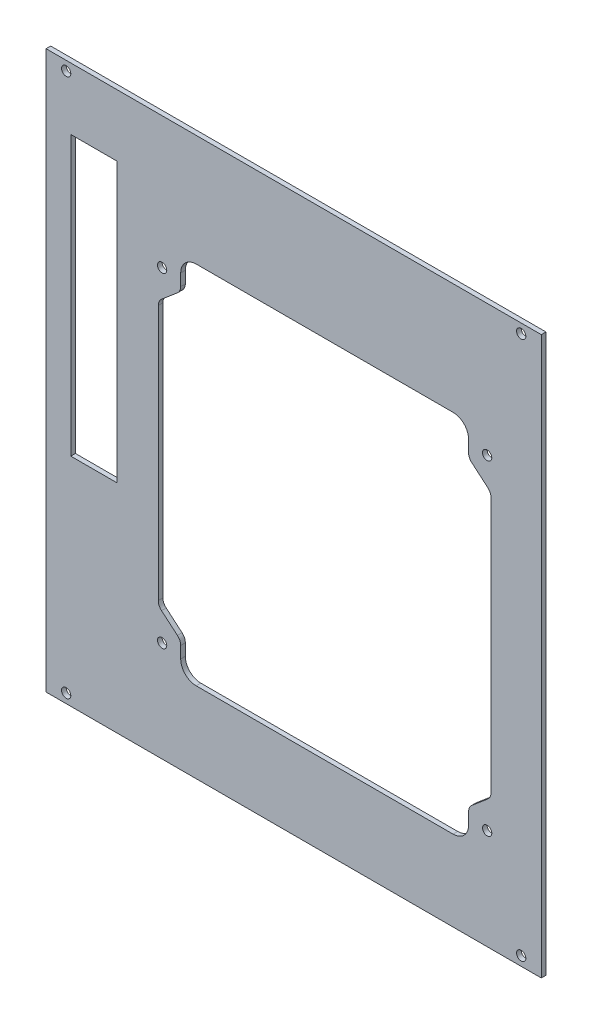
from build123d import *

# Parameters (mm, degrees)
SKETCH_1_W      = 1600
SKETCH_1_H      = 1800
SKETCH_1_R      = 15
SKETCH_1_W_2    = 150
SKETCH_1_H_2    = 900
EXTRUDE_1_DEPTH = 3
SCALE_1_SCALE_X = 0.1
SCALE_1_SCALE_Y = 0.1
SCALE_1_SCALE_Z = 0.5


with BuildPart() as part:
    # 草图1 → 凸台-拉伸1 (new body)
    with BuildSketch(Plane.XY):
        with Locations((-690.069262504, 0)):
            Rectangle(SKETCH_1_W, SKETCH_1_H)
        with Locations((-1425.069262504, 870)):
            Circle(SKETCH_1_R, mode=Mode.SUBTRACT)
        with Locations((-1425.069262504, -870)):
            Circle(SKETCH_1_R, mode=Mode.SUBTRACT)
        with Locations((44.930737496, -870)):
            Circle(SKETCH_1_R, mode=Mode.SUBTRACT)
        with Locations((44.930737496, 870)):
            Circle(SKETCH_1_R, mode=Mode.SUBTRACT)
        with Locations((-65.069262504, -575)):
            Circle(SKETCH_1_R, mode=Mode.SUBTRACT)
        with Locations((-65.069262504, 475)):
            Circle(SKETCH_1_R, mode=Mode.SUBTRACT)
        with Locations((-1115.069262504, 475)):
            Circle(SKETCH_1_R, mode=Mode.SUBTRACT)
        with Locations((-1115.069262504, -575)):
            Circle(SKETCH_1_R, mode=Mode.SUBTRACT)
        with BuildLine():
            Line((-175.069262502, -640.000000303), (-1005.069262204, -640.000000303))
            ThreePointArc((-1005.069262204, -640.000000303), (-1040.424601475, -625.355339275), (-1055.069262504, -590.000000004))
            Line((-1055.069262504, -590.000000004), (-1055.069262504, -552.101655833))
            ThreePointArc((-1055.069262504, -552.101655833), (-1057.844120021, -539.500401262), (-1065.655370289, -529.230259088))
            Line((-1065.655370289, -529.230259088), (-1116.983160822, -485.661770284))
            ThreePointArc((-1116.983160822, -485.661770284), (-1124.794411091, -475.39162811), (-1127.569268608, -462.790373539))
            Line((-1127.569268608, -462.790373539), (-1127.569268608, 362.790373539))
            ThreePointArc((-1127.569268608, 362.790373539), (-1124.794411091, 375.39162811), (-1116.983160822, 385.661770284))
            Line((-1116.983160822, 385.661770284), (-1065.655370289, 429.230259088))
            ThreePointArc((-1065.655370289, 429.230259088), (-1057.844120021, 439.500401262), (-1055.069262504, 452.101655833))
            Line((-1055.069262504, 452.101655833), (-1055.069262504, 490.000000004))
            ThreePointArc((-1055.069262504, 490.000000004), (-1040.424601475, 525.355339275), (-1005.069262204, 540.000000303))
            Line((-1005.069262204, 540.000000303), (-175.069262502, 540.000000303))
            ThreePointArc((-175.069262502, 540.000000303), (-139.713923231, 525.355339275), (-125.069262203, 490.000000003))
            Line((-125.069262203, 490.000000003), (-125.069262203, 452.101655833))
            ThreePointArc((-125.069262203, 452.101655833), (-122.294404686, 439.500401262), (-114.483154417, 429.230259088))
            Line((-114.483154417, 429.230259088), (-63.155363884, 385.661770284))
            ThreePointArc((-63.155363884, 385.661770284), (-55.344113616, 375.39162811), (-52.569256099, 362.790373539))
            Line((-52.569256099, 362.790373539), (-52.569256099, -462.790373539))
            ThreePointArc((-52.569256099, -462.790373539), (-55.344113616, -475.39162811), (-63.155363884, -485.661770284))
            Line((-63.155363884, -485.661770284), (-114.483154418, -529.230259088))
            ThreePointArc((-114.483154418, -529.230259088), (-122.294404686, -539.500401262), (-125.069262203, -552.101655834))
            Line((-125.069262203, -552.101655834), (-125.069262203, -590.000000004))
            ThreePointArc((-125.069262203, -590.000000004), (-139.713923231, -625.355339275), (-175.069262502, -640.000000303))
        make_face(mode=Mode.SUBTRACT)
        with Locations((-1335.069262504, 250)):
            Rectangle(SKETCH_1_W_2, SKETCH_1_H_2, mode=Mode.SUBTRACT)
    extrude(amount=EXTRUDE_1_DEPTH)


with BuildPart() as part_1:
    # 缩放比例1: scaled about (-713.887126751, 18.384579876, 1.5)
    add(part.part.scale((SCALE_1_SCALE_X, SCALE_1_SCALE_Y, SCALE_1_SCALE_Z), about=(-713.887126751, 18.384579876, 1.5)))


solid = part_1.part
